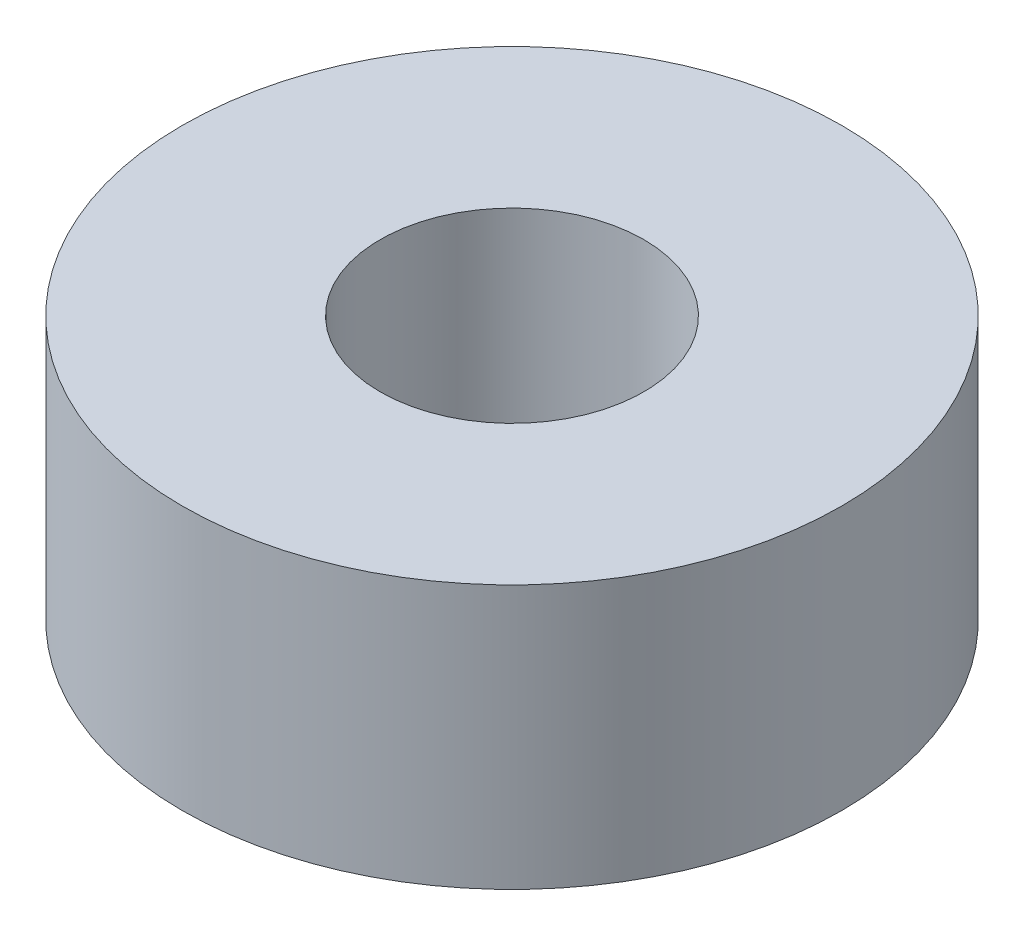
from build123d import *

# Parameters (mm, degrees)
SKETCH1_R           = 12.5
SKETCH1_R_2         = 5
BOSS_EXTRUDE1_DEPTH = 10


with BuildPart() as part:
    # Sketch1 → Boss-Extrude1 (new body)
    with BuildSketch(Plane(origin=(0, 0, 0), x_dir=(1, 0, 0), z_dir=(0, 1, 0))):
        Circle(SKETCH1_R)
        Circle(SKETCH1_R_2, mode=Mode.SUBTRACT)
    extrude(amount=BOSS_EXTRUDE1_DEPTH)


solid = part.part
